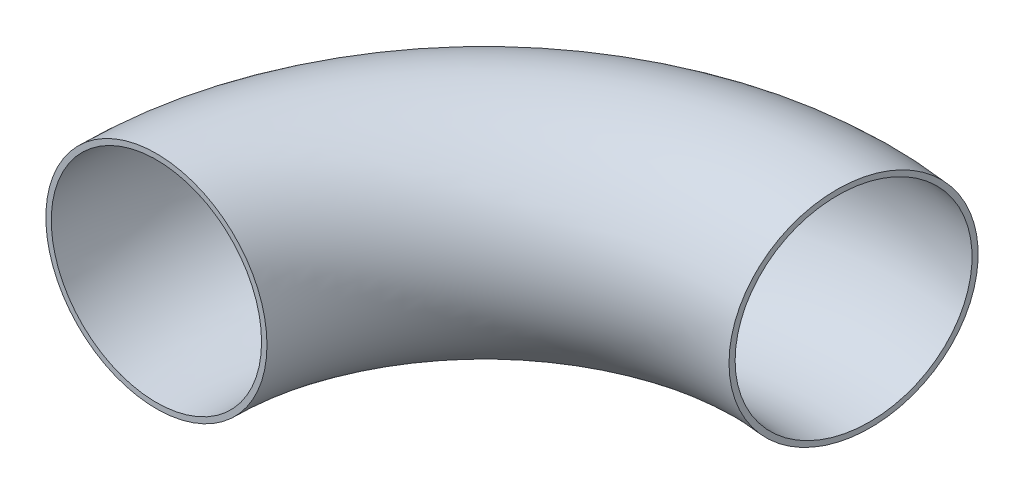
from build123d import *

# Parameters (mm, degrees)
SKETCH1_R   = 25.4
SKETCH1_R_2 = 24.1554


with BuildPart() as part:
    # Sweep3: sweep along a path in Sketch3
    with BuildLine(Plane(origin=(0, 0, 0), x_dir=(1, 0, 0), z_dir=(0, 1, 0))) as sweep3_path:
        ThreePointArc((0, 0), (25.811877132, 56.757211967), (85.553208555, 74.606789864))
    # Sketch1 → Sweep3 (sweep)
    with BuildSketch(Plane.XY):
        Circle(SKETCH1_R)
        Circle(SKETCH1_R_2, mode=Mode.SUBTRACT)
    sweep(path=sweep3_path.line)


solid = part.part
